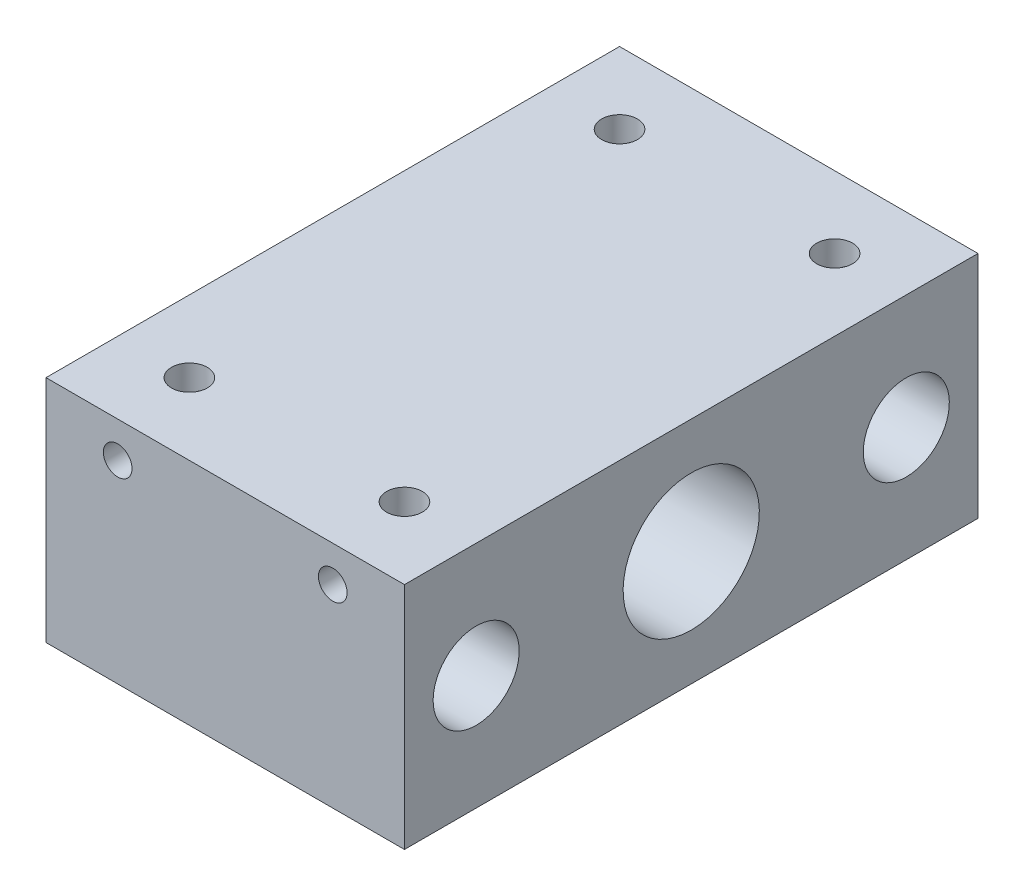
from build123d import *

# Parameters (mm, degrees)
SKETCH_1_W          = 50
SKETCH_1_H          = 32
SKETCH_1_R          = 2
EXTRUDE_1_DEPTH     = 80
SKETCH_2_R          = 2.5
CUT_EXTRUDE_1_DEPTH = 80
SKETCH_3_R          = 6
SKETCH_3_R_2        = 9.5
CUT_EXTRUDE_7_DEPTH = 80


with BuildPart() as part:
    # 草图1 → 凸台-拉伸1 (new body)
    with BuildSketch(Plane.XY):
        with Locations((0.559701493, -3.126865672)):
            Rectangle(SKETCH_1_W, SKETCH_1_H)
        with Locations((-14.440298507, 7.873134328)):
            Circle(SKETCH_1_R, mode=Mode.SUBTRACT)
        with Locations((15.559701493, 7.873134328)):
            Circle(SKETCH_1_R, mode=Mode.SUBTRACT)
    extrude(amount=EXTRUDE_1_DEPTH)

    # 草图2 → 切除-拉伸1 (cut)
    with BuildSketch(Plane(origin=(0, 12.873134328, 0), x_dir=(1, 0, 0), z_dir=(0, 1, 0))):
        with Locations((-14.440298507, -10)):
            Circle(SKETCH_2_R)
        with Locations((15.559701493, -10)):
            Circle(SKETCH_2_R)
        with Locations((15.559701493, -70)):
            Circle(SKETCH_2_R)
        with Locations((-14.440298507, -70)):
            Circle(SKETCH_2_R)
    extrude(amount=-CUT_EXTRUDE_1_DEPTH, mode=Mode.SUBTRACT)

    # 草图3 → 切除-拉伸7 (cut)
    with BuildSketch(Plane.ZY.offset(24.440298507)):
        with Locations((10, -3.126865672)):
            Circle(SKETCH_3_R)
        with Locations((70, -3.126865672)):
            Circle(SKETCH_3_R)
        with Locations((40, -3.126865672)):
            Circle(SKETCH_3_R_2)
    extrude(amount=-CUT_EXTRUDE_7_DEPTH, mode=Mode.SUBTRACT)


solid = part.part
